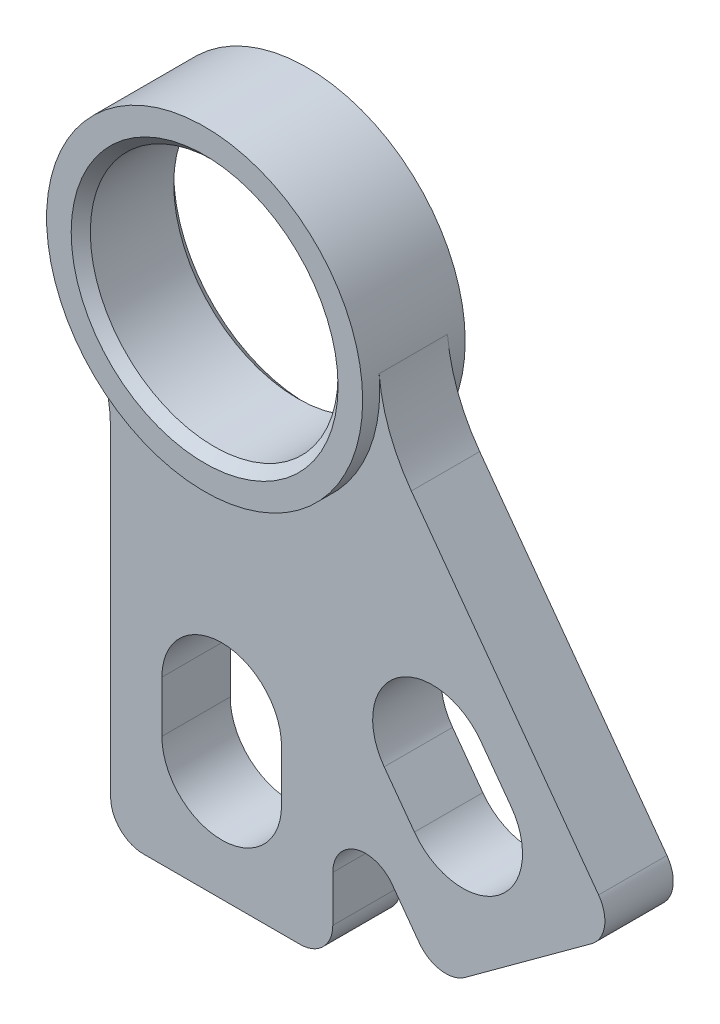
from build123d import *

# Parameters (mm, degrees)
SKETCH1_R           = 11.5062
BOSS_EXTRUDE2_DEPTH = 4.7625
BOSS_EXTRUDE3_DEPTH = 3.175
FILLET1_R           = 3.048
CHAMFER1_SIZE       = 0.889


with BuildPart() as part:
    # Sketch1 → Boss-Extrude2 (new, symmetric)
    with BuildSketch(Plane.XY):
        with BuildLine():
            ThreePointArc((14.621497696, 1.322663433), (-4.556441994, 13.956234084), (-12.585193267, -7.559797873))
            ThreePointArc((-12.585193267, -7.559797873), (4.556441994, -13.956234084), (14.621497696, 1.322663433))
        make_face()
        Circle(SKETCH1_R, mode=Mode.SUBTRACT)
    extrude(amount=BOSS_EXTRUDE2_DEPTH, both=True)

    # Sketch1_4 → Boss-Extrude3 (add, symmetric)
    with BuildSketch(Plane.XY):
        with BuildLine():
            ThreePointArc((-12.585193267, -7.559797873), (-10.89585042, -11.492870345), (-10.31875, -15.734319794))
            Line((-10.31875, -15.734319794), (-10.31875, -48.26))
            Line((-10.31875, -48.26), (10.31875, -48.26))
            Line((10.31875, -48.26), (10.31875, -31.605996662))
            Line((10.31875, -31.605996662), (20.145719857, -45.051683354))
            Line((20.145719857, -45.051683354), (36.80750102, -32.874185469))
            Line((36.80750102, -32.874185469), (17.615185966, -6.614426983))
            ThreePointArc((17.615185966, -6.614426983), (15.578373329, -2.849545496), (14.621497696, 1.322663433))
            ThreePointArc((14.621497696, 1.322663433), (4.556441994, -13.956234084), (-12.585193267, -7.559797873))
        make_face()
        with BuildLine():
            ThreePointArc((5.55625, -37.94125), (0, -43.4975), (-5.55625, -37.94125))
            Line((-5.55625, -37.94125), (-5.55625, -33.17875))
            ThreePointArc((-5.55625, -33.17875), (0, -27.6225), (5.55625, -33.17875))
            Line((5.55625, -33.17875), (5.55625, -37.94125))
        make_face(mode=Mode.SUBTRACT)
        with BuildLine():
            ThreePointArc((26.873725655, -27.353486707), (25.666418619, -35.117907989), (17.901997337, -33.910600953))
            Line((17.901997337, -33.910600953), (15.091805517, -30.065574531))
            ThreePointArc((15.091805517, -30.065574531), (16.299112553, -22.301153249), (24.063533835, -23.508460285))
            Line((24.063533835, -23.508460285), (26.873725655, -27.353486707))
        make_face(mode=Mode.SUBTRACT)
    extrude(amount=BOSS_EXTRUDE3_DEPTH, both=True)

    # Fillet1
    fillet1_edges = [part.edges().sort_by_distance(p)[0] for p in [
        (-10.31875, -48.26, 0),
        (36.80750102, -32.874185469, 0),
        (10.31875, -31.605996662, 0),
        (10.31875, -48.26, 0),
        (20.145719857, -45.051683354, 0),
    ]]
    fillet(fillet1_edges, radius=FILLET1_R)

    # Chamfer1
    chamfer1_edges = [part.edges().sort_by_distance(p)[0] for p in [
        (-11.5062, 0, -4.7625),
        (-11.5062, 0, 4.7625),
    ]]
    chamfer(chamfer1_edges, length=CHAMFER1_SIZE)


solid = part.part
